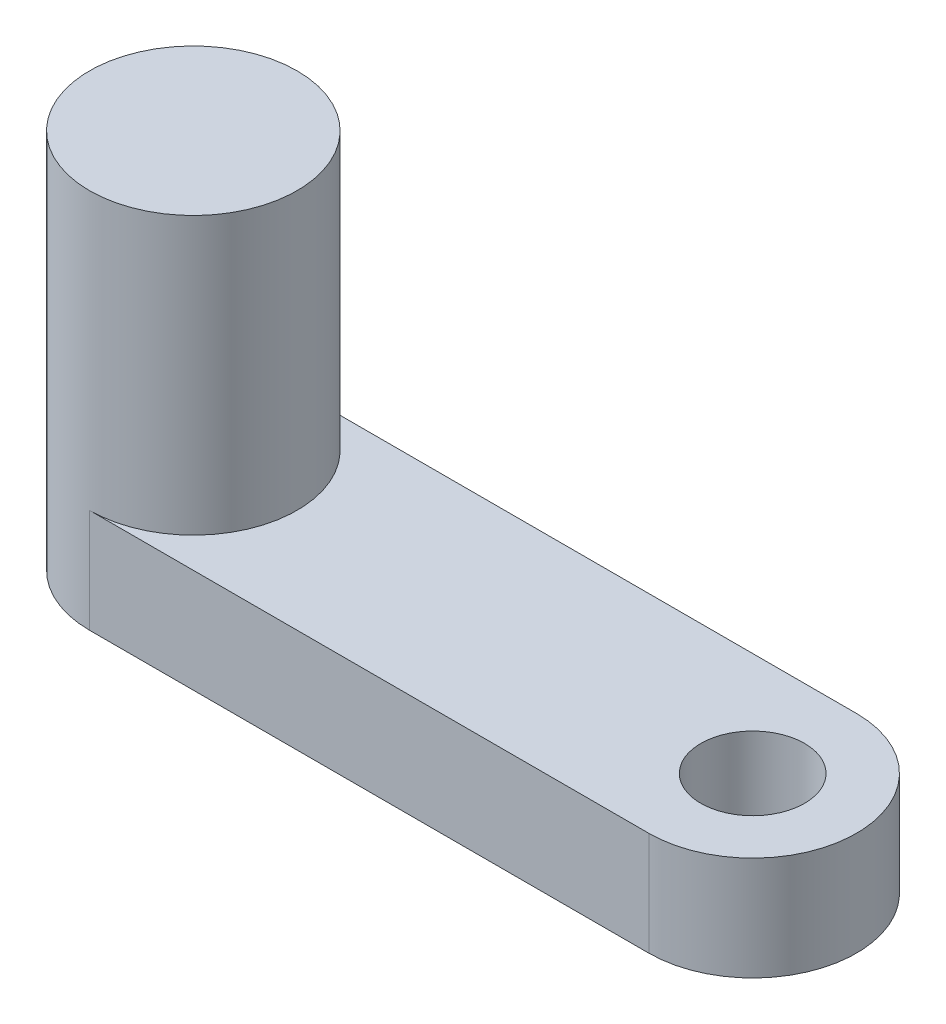
from build123d import *

# Parameters (mm, degrees)
SKETCH1_R           = 3
BOSS_EXTRUDE1_DEPTH = 9
SKETCH4_R           = 3
BOSS_EXTRUDE3_DEPTH = 2
SKETCH6_R           = 1.5
BOSS_EXTRUDE4_DEPTH = 3
SKETCH7_R           = 1.5
CUT_EXTRUDE3_DEPTH  = 10


with BuildPart() as part:
    # Sketch1 → Boss-Extrude1 (new body)
    with BuildSketch(Plane(origin=(0, 0, 0), x_dir=(1, 0, 0), z_dir=(0, 1, 0))):
        Circle(SKETCH1_R)
    extrude(amount=BOSS_EXTRUDE1_DEPTH)

    # Sketch4 → Boss-Extrude3 (add)
    with BuildSketch(Plane.XZ):
        Circle(SKETCH4_R)
    extrude(amount=BOSS_EXTRUDE3_DEPTH)

    # Sketch6 → Boss-Extrude4 (add)
    with BuildSketch(Plane.XZ.offset(2)):
        with BuildLine():
            Line((16.163723902, 3), (0, 3))
            ThreePointArc((0, 3), (2.121320344, 2.121320344), (3, 0))
            ThreePointArc((3, 0), (2.121320344, -2.121320344), (0, -3))
            Line((0, -3), (16.163723902, -3))
            ThreePointArc((16.163723902, -3), (19.163723902, 0), (16.163723902, 3))
        make_face()
        with Locations((16.163723902, 0)):
            Circle(SKETCH6_R, mode=Mode.SUBTRACT)
    extrude(amount=-BOSS_EXTRUDE4_DEPTH)

    # Sketch7 → Cut-Extrude3 (cut)
    with BuildSketch(Plane.XZ.offset(2)):
        Circle(SKETCH7_R)
    extrude(amount=-CUT_EXTRUDE3_DEPTH, mode=Mode.SUBTRACT)


solid = part.part
